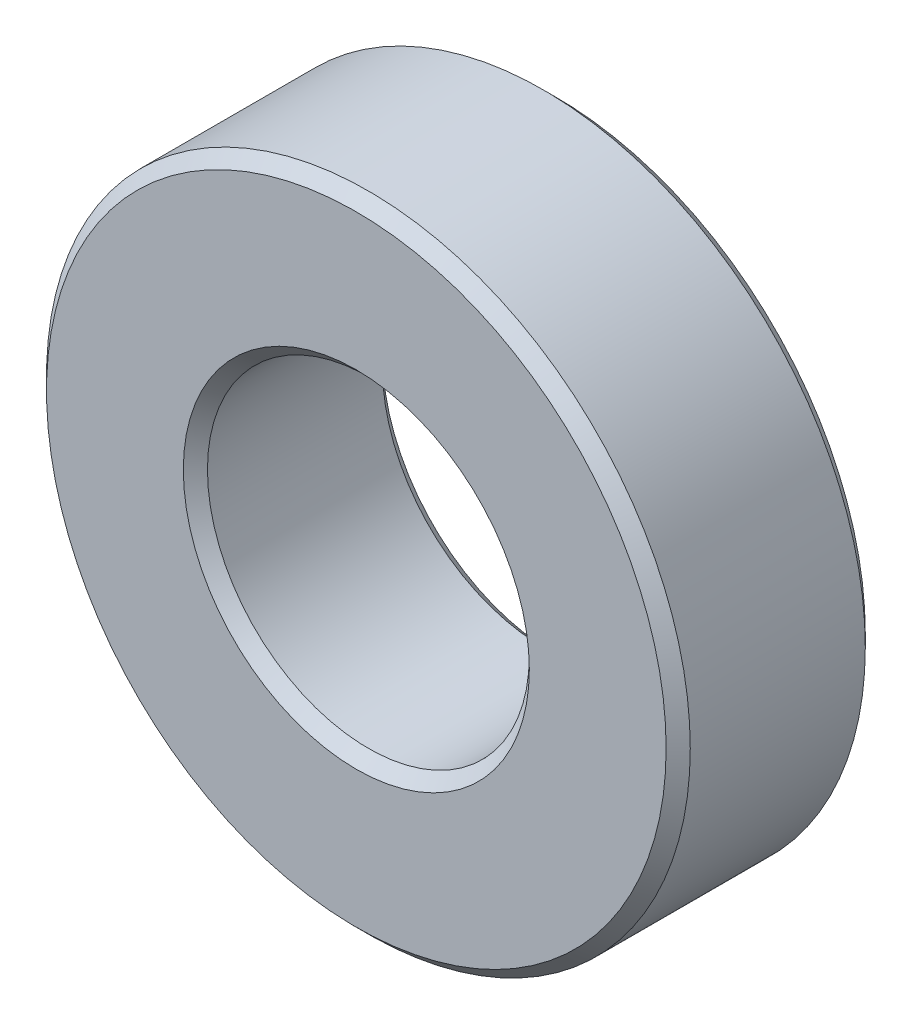
from build123d import *

# Parameters (mm, degrees)
SKETCH1_R           = 8
SKETCH1_R_2         = 4
BOSS_EXTRUDE1_DEPTH = 4.95
CHAMFER1_SIZE       = 0.3


with BuildPart() as part:
    # Sketch1 → Boss-Extrude1 (new body)
    with BuildSketch(Plane.XY):
        Circle(SKETCH1_R)
        Circle(SKETCH1_R_2, mode=Mode.SUBTRACT)
    extrude(amount=BOSS_EXTRUDE1_DEPTH)

    # Chamfer1
    chamfer1_edges = [part.edges().sort_by_distance(p)[0] for p in [
        (-8, 0, 0),
        (-8, 0, 4.95),
        (-4, 0, 0),
        (-4, 0, 4.95),
    ]]
    chamfer(chamfer1_edges, length=CHAMFER1_SIZE)


solid = part.part
